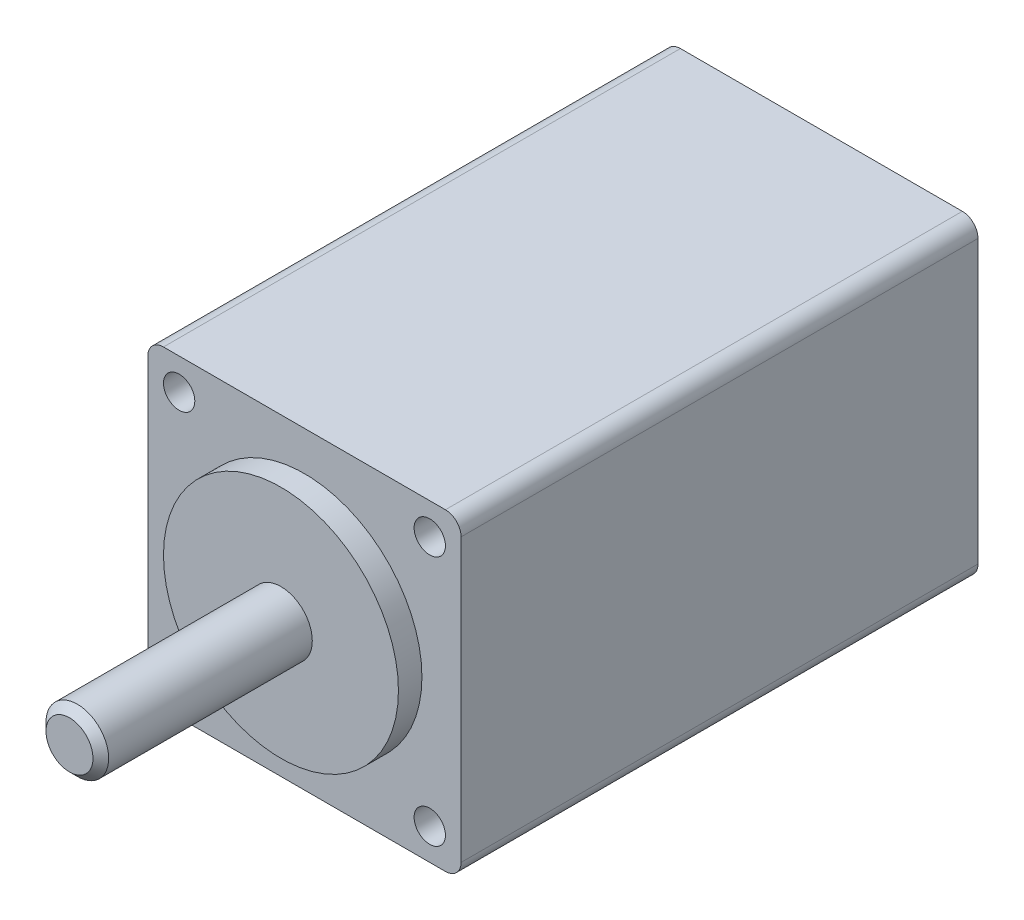
from build123d import *

# Parameters (mm, degrees)
SKETCH1_W           = 20
SKETCH1_H           = 20
BOSS_EXTRUDE1_DEPTH = 33
SKETCH2_R           = 7.5
BOSS_EXTRUDE2_DEPTH = 1.5
SKETCH3_R           = 2
CUT_EXTRUDE1_DEPTH  = 35.5
FILLET1_R           = 1
SKETCH4_R           = 1
CUT_EXTRUDE2_DEPTH  = 3
SKETCH5_W           = 48
SKETCH5_H           = 2
CHAMFER1_SIZE       = 0.5


with BuildPart() as part:
    # Sketch1 → Boss-Extrude1 (new body)
    with BuildSketch(Plane.XY):
        Rectangle(SKETCH1_W, SKETCH1_H)
    extrude(amount=-BOSS_EXTRUDE1_DEPTH)

    # Sketch2 → Boss-Extrude2 (add)
    with BuildSketch(Plane.XY):
        Circle(SKETCH2_R)
    extrude(amount=BOSS_EXTRUDE2_DEPTH)

    # Sketch3 → Cut-Extrude1 (cut, through all)
    with BuildSketch(Plane.XY.offset(1.5)):
        Circle(SKETCH3_R)
    extrude(amount=-CUT_EXTRUDE1_DEPTH, mode=Mode.SUBTRACT)

    # Fillet1
    fillet1_edges = [part.edges().sort_by_distance(p)[0] for p in [
        (-10, 10, -16.5),
        (10, 10, -16.5),
        (10, -10, -16.5),
        (-10, -10, -16.5),
    ]]
    fillet(fillet1_edges, radius=FILLET1_R)

    # Sketch4 → Cut-Extrude2 (cut)
    with BuildSketch(Plane.XY):
        with Locations((8, 8)):
            Circle(SKETCH4_R)
        with Locations((-8, 8)):
            Circle(SKETCH4_R)
        with Locations((-8, -8)):
            Circle(SKETCH4_R)
        with Locations((8, -8)):
            Circle(SKETCH4_R)
    extrude(amount=-CUT_EXTRUDE2_DEPTH, mode=Mode.SUBTRACT)


with BuildPart() as body_2:
    # Sketch5 → Revolve1 (revolve)
    with BuildSketch(Plane(origin=(0, 0, 0), x_dir=(0, 0, -1), z_dir=(1, 0, 0))):
        with Locations((9, 1)):
            Rectangle(SKETCH5_W, SKETCH5_H)
    revolve(axis=Axis((0, 0, 32.857523653), (0, 0, -1)))

    # Chamfer1
    chamfer1_edges = [body_2.edges().sort_by_distance(p)[0] for p in [
        (0, -2, 15),
        (0, -2, -33),
    ]]
    chamfer(chamfer1_edges, length=CHAMFER1_SIZE)


solid = Compound([part.part, body_2.part])
